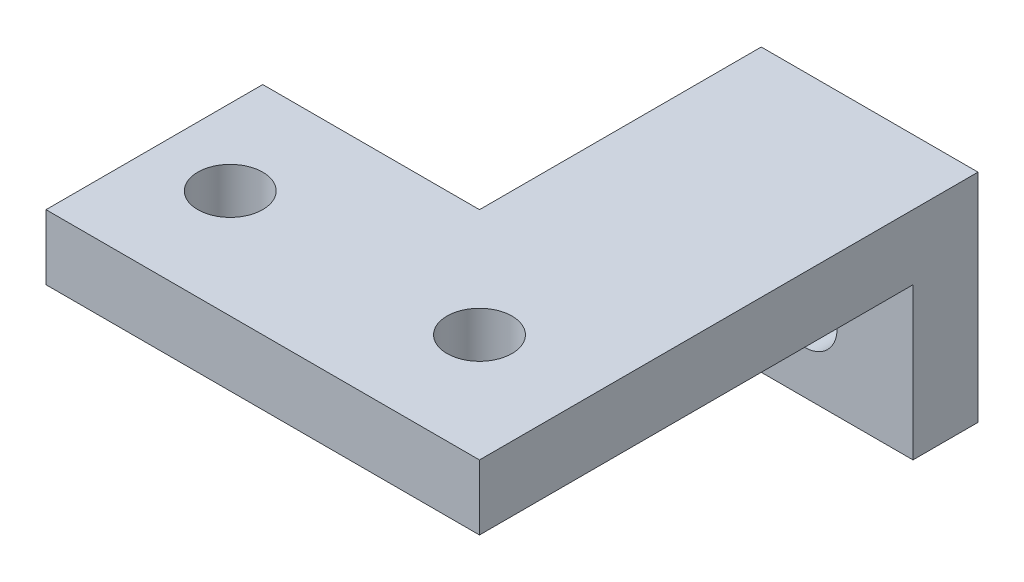
from build123d import *

# Parameters (mm, degrees)
BOSS_EXTRUDE1_DEPTH = 3
SKETCH7_W           = 10
SKETCH7_H           = 3
BOSS_EXTRUDE2_DEPTH = 7
CUT_EXTRUDE1_REACH  = 25
SKETCH8_R           = 1.5
CUT_EXTRUDE2_REACH  = 12
SKETCH12_R          = 1.5


with BuildPart() as part:
    # Sketch1 → Boss-Extrude1 (new body)
    with BuildSketch(Plane(origin=(0, 0, 0), x_dir=(1, 0, 0), z_dir=(0, 1, 0))):
        Polygon((0, 0), (20, 0), (20, 23), (10, 23), (10, 10), (0, 10), align=None)
    extrude(amount=BOSS_EXTRUDE1_DEPTH)

    # Sketch7 → Boss-Extrude2 (add)
    with BuildSketch(Plane.XZ):
        with Locations((15, -21.5)):
            Rectangle(SKETCH7_W, SKETCH7_H)
    extrude(amount=BOSS_EXTRUDE2_DEPTH)

    # Sketch8 → Cut-Extrude1 (cut, up to next)
    with BuildSketch(Plane(origin=(0, 0, -23), x_dir=(-1, 0, 0), z_dir=(0, 0, -1)), mode=Mode.PRIVATE) as cut_extrude1_sk1:
        with Locations((-15, -3.5)):
            Circle(SKETCH8_R)
    cut_extrude1_tool1 = extrude(cut_extrude1_sk1.sketch, amount=-CUT_EXTRUDE1_REACH, mode=Mode.PRIVATE) & part.part
    add(cut_extrude1_tool1.solids().sort_by_distance((15, -3.5, -23))[0], mode=Mode.SUBTRACT)

    # Sketch12 → Cut-Extrude2 (cut, up to next)
    with BuildSketch(Plane(origin=(0, 3, 0), x_dir=(1, 0, 0), z_dir=(0, 1, 0)), mode=Mode.PRIVATE) as cut_extrude2_sk1:
        with Locations((15, 5)):
            Circle(SKETCH12_R)
    cut_extrude2_tool1 = extrude(cut_extrude2_sk1.sketch, amount=-CUT_EXTRUDE2_REACH, mode=Mode.PRIVATE) & part.part
    add(cut_extrude2_tool1.solids().sort_by_distance((15, 3, -5))[0], mode=Mode.SUBTRACT)
    # Sketch12 → Cut-Extrude2 (cut, up to next)
    with BuildSketch(Plane(origin=(0, 3, 0), x_dir=(1, 0, 0), z_dir=(0, 1, 0)), mode=Mode.PRIVATE) as cut_extrude2_sk2:
        with Locations((3.5, 5)):
            Circle(SKETCH12_R)
    cut_extrude2_tool2 = extrude(cut_extrude2_sk2.sketch, amount=-CUT_EXTRUDE2_REACH, mode=Mode.PRIVATE) & part.part
    add(cut_extrude2_tool2.solids().sort_by_distance((3.5, 3, -5))[0], mode=Mode.SUBTRACT)


solid = part.part
